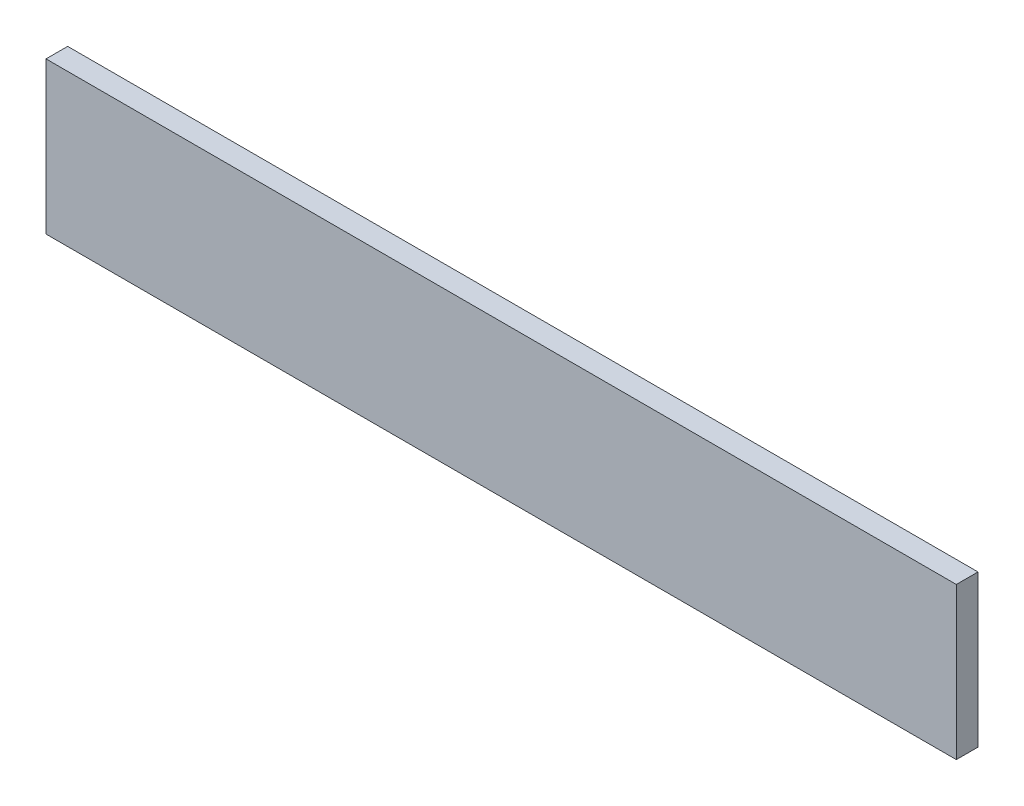
from build123d import *

# Parameters (mm, degrees)
SKETCH1_W           = 533.4
SKETCH1_H           = 88.9
BOSS_EXTRUDE1_DEPTH = 12.7


with BuildPart() as part:
    # Sketch1 → Boss-Extrude1 (new body)
    with BuildSketch(Plane.XY):
        with Locations((74.829496403, -0.831438849)):
            Rectangle(SKETCH1_W, SKETCH1_H)
    extrude(amount=BOSS_EXTRUDE1_DEPTH)


solid = part.part
